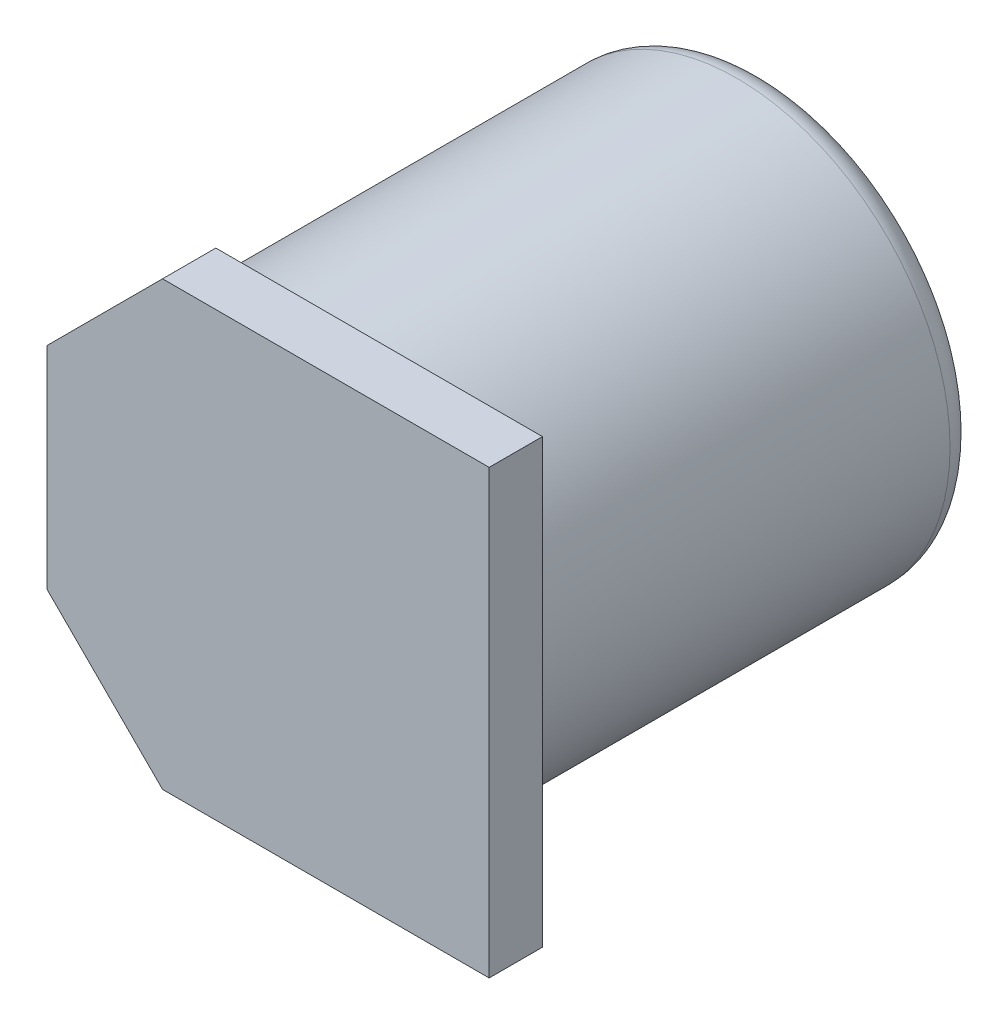
from build123d import *

# Parameters (mm, degrees)
BOSS_EXTRUDE1_DEPTH = 1
SKETCH2_R           = 4
BOSS_EXTRUDE2_DEPTH = 8.3
FILLET2_R           = 0.5


with BuildPart() as part:
    # Sketch1 → Boss-Extrude1 (new body)
    with BuildSketch(Plane.XY):
        Polygon((-4.15, 1.98), (-1.98, 4.15), (4.15, 4.15), (4.15, -4.15), (-1.98, -4.15), (-4.15, -1.98), align=None)
    extrude(amount=BOSS_EXTRUDE1_DEPTH)

    # Sketch2 → Boss-Extrude2 (add)
    with BuildSketch(Plane.XY):
        Circle(SKETCH2_R)
    extrude(amount=-BOSS_EXTRUDE2_DEPTH)

    # Fillet2
    fillet2_edges = [part.edges().sort_by_distance(p)[0] for p in [
        (-4, 0, -8.3),
    ]]
    fillet(fillet2_edges, radius=FILLET2_R)


solid = part.part
